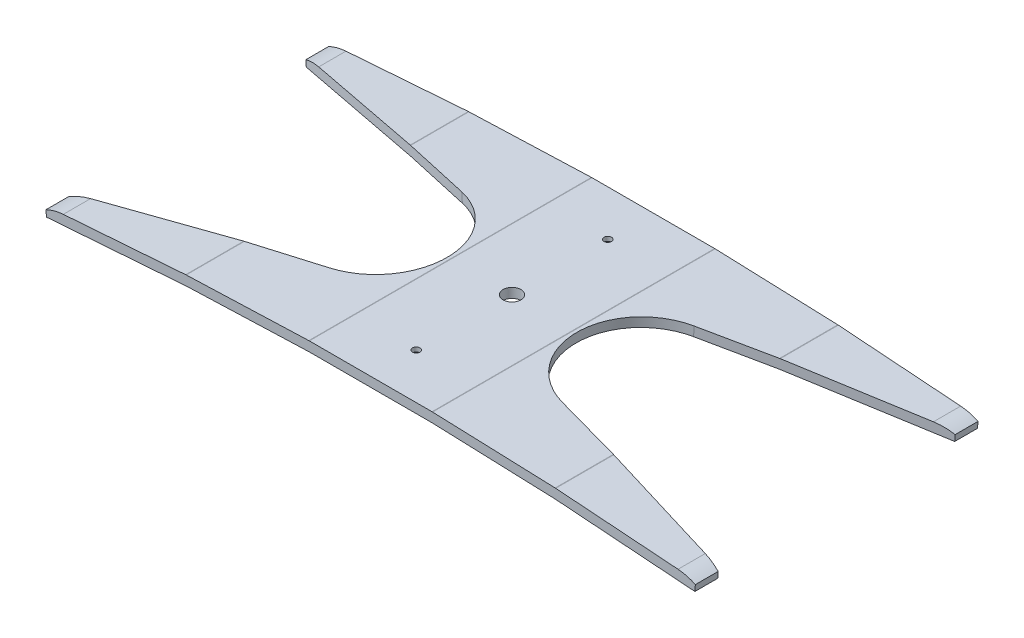
from build123d import *

# Parameters (mm, degrees)
BOSS_EXTRUDE1_DEPTH                       = 74.93
CUT_EXTRUDE1_START                        = -13.499231569
CUT_EXTRUDE1_DEPTH                        = 27.344407223
F_5_32_0_15625_DIAMETER_HOLE1_D           = 3.96875
F_5_32_0_15625_DIAMETER_HOLE1_DEPTH       = 5.08
F_5_32_0_15625_DIAMETER_HOLE1_CSINK_D     = 10.668
F_5_32_0_15625_DIAMETER_HOLE1_CSINK_ANGLE = 100
F_3_8_0_375_DIAMETER_HOLE1_D              = 9.525
F_3_8_0_375_DIAMETER_HOLE1_DEPTH          = 5.08


with BuildPart() as part:
    # Sketch6 → Boss-Extrude1 (new body, symmetric)
    with BuildSketch(Plane.XY):
        with BuildLine():
            Line((0, 0), (0, 5.08))
            Line((0, 5.08), (32.525659605, 5.08))
            ThreePointArc((32.525659605, 5.08), (32.664283789, 5.07873896), (32.80286209, 5.074956256))
            Line((32.80286209, 5.074956256), (65.30699268, 3.891728742))
            Line((65.30699268, 3.891728742), (97.81112327, 2.708501229))
            ThreePointArc((97.81112327, 2.708501229), (97.949609823, 2.702198114), (98.087958789, 2.693376674))
            Line((98.087958789, 2.693376674), (130.527530834, 0.328488024))
            Line((130.527530834, 0.328488024), (162.967102879, -2.036400627))
            ThreePointArc((162.967102879, -2.036400627), (167.673823883, -2.829176028), (172.14912896, -4.488501164))
            Line((172.14912896, -4.488501164), (171.909045825, -7.781761568))
            Line((171.909045825, -7.781761568), (130.158172165, -4.738066444))
            Line((130.158172165, -4.738066444), (97.71860012, -2.373177794))
            ThreePointArc((97.71860012, -2.373177794), (97.672483798, -2.370237314), (97.626321614, -2.368136275))
            Line((97.626321614, -2.368136275), (65.122191024, -1.184908762))
            Line((65.122191024, -1.184908762), (32.618060434, -0.001681248))
            ThreePointArc((32.618060434, -0.001681248), (32.571867667, -0.000420347), (32.525659605, 0))
            Line((32.525659605, 0), (0, 0))
        make_face()
    boss_extrude1 = extrude(amount=BOSS_EXTRUDE1_DEPTH, both=True)

    # Sketch11 → Cut-Extrude1 (cut)
    with BuildSketch(Plane(origin=(0.344497228, 4.725525927, 0), x_dir=(0.997353242, -0.072708399, 0), z_dir=(0.072708399, 0.997353242, 0)).offset(CUT_EXTRUDE1_START)):
        with BuildLine():
            Line((172.019843553, 62.831668461), (172.019843553, -62.831668461))
            Line((172.019843553, -62.831668461), (61.19754378, -34.980240535))
            ThreePointArc((61.19754378, -34.980240535), (33.920641331, 0), (61.19754378, 34.980240535))
            Line((61.19754378, 34.980240535), (172.019843553, 62.831668461))
        make_face()
    cut_extrude1 = extrude(amount=CUT_EXTRUDE1_DEPTH, mode=Mode.SUBTRACT)

    # Mirror1: Boss-Extrude1, Cut-Extrude1 across plane
    add(boss_extrude1.mirror(Plane(origin=(0, 0, 0), x_dir=(0, 0, 1), z_dir=(1, 0, 0))))
    add(cut_extrude1.mirror(Plane(origin=(0, 0, 0), x_dir=(0, 0, 1), z_dir=(1, 0, 0))), mode=Mode.SUBTRACT)

    # 5/32 (0.15625) Diameter Hole1
    with Locations(Plane(origin=(-1.862802154, 0, 42.848601798), x_dir=(1, 0, 0), z_dir=(0, -1, 0))):
        with Locations((1.862802154, -93.648601798), (1.862802154, 7.951398202)):
            CounterSinkHole(F_5_32_0_15625_DIAMETER_HOLE1_D / 2, F_5_32_0_15625_DIAMETER_HOLE1_CSINK_D / 2, depth=F_5_32_0_15625_DIAMETER_HOLE1_DEPTH, counter_sink_angle=F_5_32_0_15625_DIAMETER_HOLE1_CSINK_ANGLE)

    # 3/8 (0.375) Diameter Hole1
    with Locations(Plane(origin=(0, 5.08, 0), x_dir=(1, 0, 0), z_dir=(0, 1, 0))):
        with Locations((0, 0)):
            Hole(F_3_8_0_375_DIAMETER_HOLE1_D / 2, depth=F_3_8_0_375_DIAMETER_HOLE1_DEPTH)


solid = part.part
